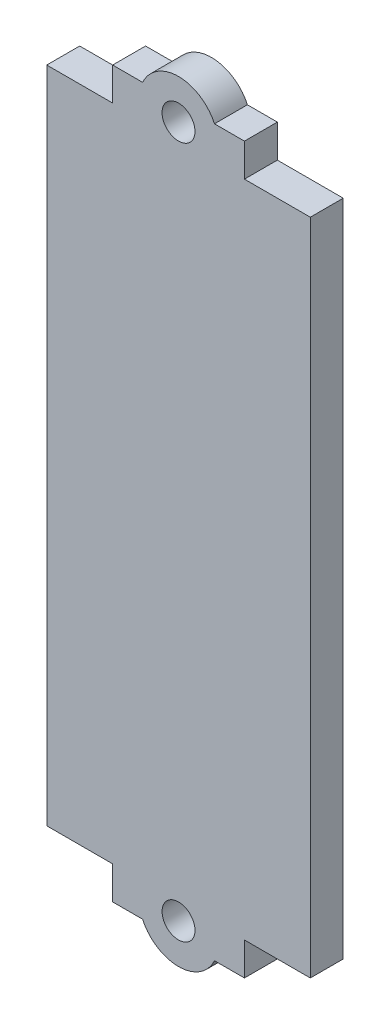
from build123d import *

# Parameters (mm, degrees)
SKETCH1_W           = 40
SKETCH1_H           = 100
BOSS_EXTRUDE1_DEPTH = 5
SKETCH2_W           = 20
SKETCH2_H           = 5
BOSS_EXTRUDE2_DEPTH = 5
SKETCH3_R           = 6
BOSS_EXTRUDE3_DEPTH = 5
SKETCH4_R           = 2.5
CUT_EXTRUDE1_DEPTH  = 5


with BuildPart() as part:
    # Sketch1 → Boss-Extrude1 (new body)
    with BuildSketch(Plane.XY):
        Rectangle(SKETCH1_W, SKETCH1_H)
    extrude(amount=BOSS_EXTRUDE1_DEPTH)

    # Sketch2 → Boss-Extrude2 (add)
    with BuildSketch(Plane(origin=(0, 50, 0), x_dir=(1, 0, 0), z_dir=(0, 1, 0))):
        with Locations((0, -2.5)):
            Rectangle(SKETCH2_W, SKETCH2_H)
    boss_extrude2 = extrude(amount=BOSS_EXTRUDE2_DEPTH)

    # Mirror1: Boss-Extrude2 across plane
    add(boss_extrude2.mirror(Plane.ZX))

    # Sketch3 → Boss-Extrude3 (add)
    with BuildSketch(Plane.XY.offset(5)):
        with Locations((0, 52.5)):
            Circle(SKETCH3_R)
    boss_extrude3 = extrude(amount=-BOSS_EXTRUDE3_DEPTH)

    # Sketch4 → Cut-Extrude1 (cut)
    with BuildSketch(Plane.XY.offset(5)):
        with Locations((0, 52.5)):
            Circle(SKETCH4_R)
    cut_extrude1 = extrude(amount=-CUT_EXTRUDE1_DEPTH, mode=Mode.SUBTRACT)

    # Mirror2: Boss-Extrude3, Cut-Extrude1 across plane
    add(boss_extrude3.mirror(Plane.ZX))
    add(cut_extrude1.mirror(Plane.ZX), mode=Mode.SUBTRACT)


solid = part.part
